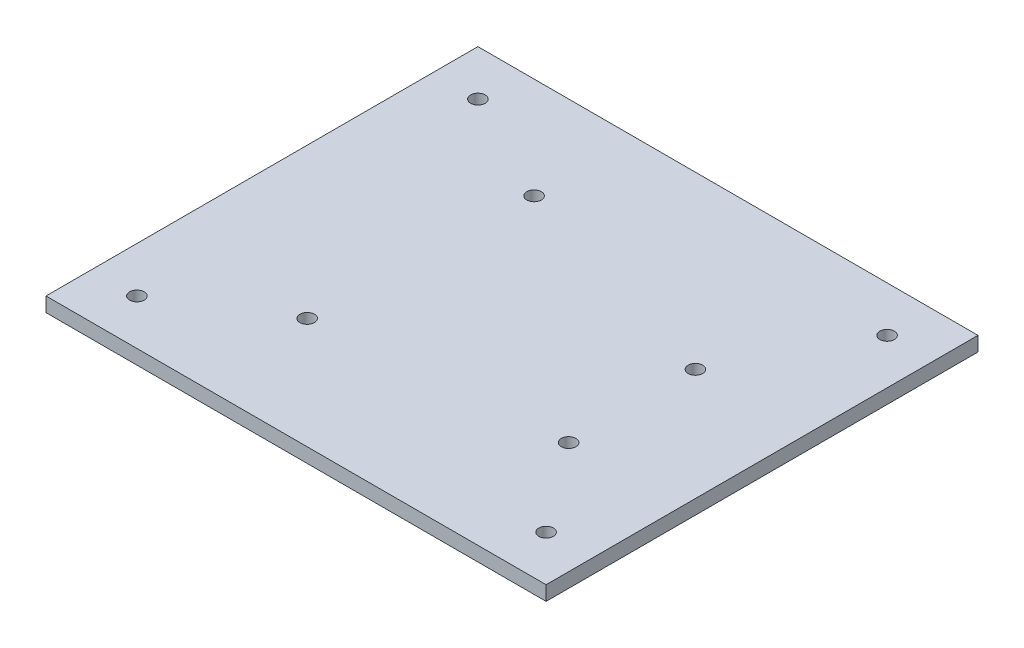
from build123d import *

# Parameters (mm, degrees)
BOSS_EXTRUDE1_DEPTH = 3.18
SKETCH2_R           = 1.6
CUT_EXTRUDE1_DEPTH  = 3.18
SKETCH3_R           = 1.6
CUT_EXTRUDE2_DEPTH  = 10


with BuildPart() as part:
    # Sketch1 → Boss-Extrude1 (new body)
    with BuildSketch(Plane(origin=(0, 0, 0), x_dir=(1, 0, 0), z_dir=(0, 1, 0))):
        Polygon((0, 0), (-55, 47.5), (-55, -47.5), align=None)
        Polygon((55, -47.5), (0, 0), (-55, -47.5), align=None)
        Polygon((55, 47.5), (0, 0), (55, -47.5), align=None)
        Polygon((55, 47.5), (-55, 47.5), (0, 0), align=None)
    extrude(amount=BOSS_EXTRUDE1_DEPTH)

    # Sketch2 → Cut-Extrude1 (cut)
    with BuildSketch(Plane(origin=(0, 3.18, 0), x_dir=(1, 0, 0), z_dir=(0, 1, 0))):
        with Locations((-20.4, 25.25)):
            Circle(SKETCH2_R)
        with Locations((-22, -23.05)):
            Circle(SKETCH2_R)
        with Locations((30.4, 9.95)):
            Circle(SKETCH2_R)
        with Locations((30.4, -17.95)):
            Circle(SKETCH2_R)
    extrude(amount=-CUT_EXTRUDE1_DEPTH, mode=Mode.SUBTRACT)

    # Sketch3 → Cut-Extrude2 (cut)
    with BuildSketch(Plane(origin=(0, 3.18, 0), x_dir=(1, 0, 0), z_dir=(0, 1, 0))):
        with Locations((45, 37.5)):
            Circle(SKETCH3_R)
        with Locations((45, -37.5)):
            Circle(SKETCH3_R)
        with Locations((-45, 37.5)):
            Circle(SKETCH3_R)
        with Locations((-45, -37.5)):
            Circle(SKETCH3_R)
    extrude(amount=-CUT_EXTRUDE2_DEPTH, mode=Mode.SUBTRACT)


solid = part.part
